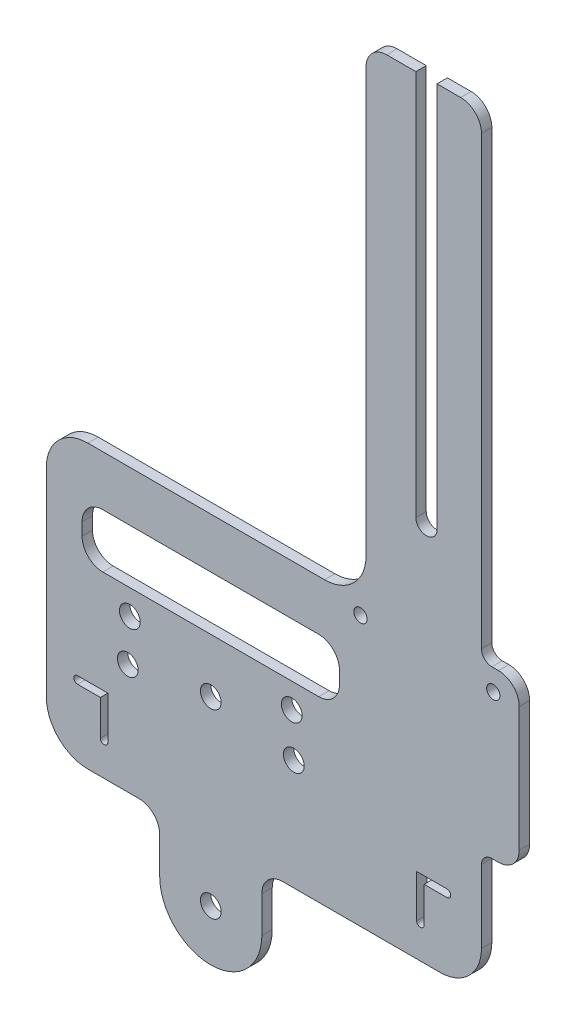
from build123d import *

# Parameters (mm, degrees)
SKETCH1_W           = 200
SKETCH1_H           = 300
SKETCH1_W_2         = 96.214780988
SKETCH1_H_2         = 20
BOSS_EXTRUDE1_DEPTH = 2.5
SKETCH2_R           = 2.5
CUT_EXTRUDE1_DEPTH  = 10
CUT_EXTRUDE3_DEPTH  = 10
CUT_EXTRUDE4_REACH  = 182.936
SKETCH5_W           = 62
SKETCH5_H           = 13
FILLET2_R           = 5
FILLET3_R           = 10
FILLET4_R           = 5
CUT_EXTRUDE6_REACH  = 182.936
SKETCH7_R           = 1.6
FILLET5_R           = 2.5
CUT_EXTRUDE7_REACH  = 182.936
SKETCH8_R           = 2.5


with BuildPart() as part:
    # Sketch1 → Boss-Extrude1 (new body)
    with BuildSketch(Plane.XY):
        Rectangle(SKETCH1_W, SKETCH1_H)
        with Locations((51.892609506, 160)):
            Rectangle(SKETCH1_W_2, SKETCH1_H_2)
    extrude(amount=BOSS_EXTRUDE1_DEPTH)

    # Sketch2 → Cut-Extrude1 (cut)
    with BuildSketch(Plane.XY.offset(2.5)):
        with Locations((-12.4, -28.75)):
            Circle(SKETCH2_R)
        with Locations((7.6, 11.65)):
            Circle(SKETCH2_R)
        with Locations((-32.4, 11.65)):
            Circle(SKETCH2_R)
        Polygon((-44.5, 1.45), (-44.5, 3.25), (-37.2, 3.25), (-37.2, -7.05), (-39, -7.05), (-39, 1.45), align=None)
        Polygon((39, 1.45), (44.5, 1.45), (44.5, 3.25), (37.2, 3.25), (37.2, -7.05), (39, -7.05), align=None)
        with BuildLine():
            Line((-44.5, 1.45), (-44.5, 3.25))
            ThreePointArc((-44.5, 3.25), (-45.4, 2.35), (-44.5, 1.45))
        make_face()
        with BuildLine():
            ThreePointArc((-37.2, -7.05), (-38.1, -7.95), (-39, -7.05))
            Line((-39, -7.05), (-37.2, -7.05))
        make_face()
        with BuildLine():
            ThreePointArc((39, -7.05), (38.1, -7.95), (37.2, -7.05))
            Line((37.2, -7.05), (39, -7.05))
        make_face()
        with BuildLine():
            ThreePointArc((44.5, 3.25), (45.4, 2.35), (44.5, 1.45))
            Line((44.5, 1.45), (44.5, 3.25))
        make_face()
    extrude(amount=-CUT_EXTRUDE1_DEPTH, mode=Mode.SUBTRACT)

    # Sketch4 → Cut-Extrude3 (cut)
    with BuildSketch(Plane.XY.offset(2.5)):
        with BuildLine():
            Line((42.1, 170), (37, 170))
            Line((37, 170), (37, 77))
            ThreePointArc((37, 77), (39.55, 74.45), (42.1, 77))
            Line((42.1, 77), (42.1, 170))
        make_face()
        with BuildLine():
            Line((25, 53), (25, 170))
            Line((25, 170), (3.785219012, 170))
            Line((3.785219012, 170), (3.785219012, 150))
            Line((3.785219012, 150), (-100, 150))
            Line((-100, 150), (-100, -150))
            Line((-100, -150), (100, -150))
            Line((100, -150), (100, 170))
            Line((100, 170), (52.8, 170))
            Line((52.8, 170), (52.8, 55))
            Line((52.8, 55), (61.9, 55))
            Line((61.9, 55), (61.9, 15))
            Line((61.9, 15), (52.8, 15))
            Line((52.8, 15), (52.8, -15))
            Line((52.8, -15), (-0.095794877, -15))
            Line((-0.095794877, -15), (-0.095794877, -28.75))
            ThreePointArc((-0.095794877, -28.75), (-12.4, -41.054205123), (-24.704205123, -28.75))
            Line((-24.704205123, -28.75), (-24.704205123, -15))
            Line((-24.704205123, -15), (-52, -15))
            Line((-52, -15), (-52, 53))
            Line((-52, 53), (25, 53))
        make_face()
    extrude(amount=-CUT_EXTRUDE3_DEPTH, mode=Mode.SUBTRACT)

    # Sketch5 → Cut-Extrude4 (cut, up to next)
    with BuildSketch(Plane.XY.offset(2.5), mode=Mode.PRIVATE) as cut_extrude4_sk1:
        with Locations((-12.4, 34.409289568)):
            Rectangle(SKETCH5_W, SKETCH5_H)
    cut_extrude4_tool1 = extrude(cut_extrude4_sk1.sketch, amount=-CUT_EXTRUDE4_REACH, mode=Mode.PRIVATE) & part.part
    add(cut_extrude4_tool1.solids().sort_by_distance((-12.4, 34.40929, 2.5))[0], mode=Mode.SUBTRACT)

    # Fillet2
    fillet2_edges = [part.edges().sort_by_distance(p)[0] for p in [
        (-43.4, 40.909289568, 1.25),
        (18.6, 40.909289568, 1.25),
        (18.6, 27.909289568, 1.25),
        (-43.4, 27.909289568, 1.25),
    ]]
    fillet(fillet2_edges, radius=FILLET2_R)

    # Fillet3
    fillet3_edges = [part.edges().sort_by_distance(p)[0] for p in [
        (52.8, -15, 1.25),
        (25, 53, 1.25),
        (-52, 53, 1.25),
        (-52, -15, 1.25),
    ]]
    fillet(fillet3_edges, radius=FILLET3_R)

    # Fillet4
    fillet4_edges = [part.edges().sort_by_distance(p)[0] for p in [
        (-0.095794877, -15, 1.25),
        (61.9, 15, 1.25),
        (61.9, 55, 1.25),
        (-24.704205123, -15, 1.25),
        (25, 170, 1.25),
        (52.8, 170, 1.25),
    ]]
    fillet(fillet4_edges, radius=FILLET4_R)

    # Sketch7 → Cut-Extrude6 (cut, up to next)
    with BuildSketch(Plane.XY.offset(2.5), mode=Mode.PRIVATE) as cut_extrude6_sk1:
        with Locations((55.65, 49.91)):
            Circle(SKETCH7_R)
    cut_extrude6_tool1 = extrude(cut_extrude6_sk1.sketch, amount=-CUT_EXTRUDE6_REACH, mode=Mode.PRIVATE) & part.part
    # Sketch7 → Cut-Extrude6 (cut, up to next)
    with BuildSketch(Plane.XY.offset(2.5), mode=Mode.PRIVATE) as cut_extrude6_sk2:
        with Locations((23.65, 49.91)):
            Circle(SKETCH7_R)
    cut_extrude6_tool2 = extrude(cut_extrude6_sk2.sketch, amount=-CUT_EXTRUDE6_REACH, mode=Mode.PRIVATE) & part.part
    add(cut_extrude6_tool1.solids().sort_by_distance((55.65, 49.91, 2.5))[0], mode=Mode.SUBTRACT)
    add(cut_extrude6_tool2.solids().sort_by_distance((23.65, 49.91, 2.5))[0], mode=Mode.SUBTRACT)

    # Fillet5
    fillet5_edges = [part.edges().sort_by_distance(p)[0] for p in [
        (52.8, 15, 1.25),
        (52.8, 55, 1.25),
    ]]
    fillet(fillet5_edges, radius=FILLET5_R)

    # Sketch8 → Cut-Extrude7 (cut, up to next)
    with BuildSketch(Plane.XY.offset(2.5), mode=Mode.PRIVATE) as cut_extrude7_sk1:
        with Locations((7.1, 21.909289568)):
            Circle(SKETCH8_R)
    cut_extrude7_tool1 = extrude(cut_extrude7_sk1.sketch, amount=-CUT_EXTRUDE7_REACH, mode=Mode.PRIVATE) & part.part
    # Sketch8 → Cut-Extrude7 (cut, up to next)
    with BuildSketch(Plane.XY.offset(2.5), mode=Mode.PRIVATE) as cut_extrude7_sk2:
        with Locations((-31.9, 21.909289568)):
            Circle(SKETCH8_R)
    cut_extrude7_tool2 = extrude(cut_extrude7_sk2.sketch, amount=-CUT_EXTRUDE7_REACH, mode=Mode.PRIVATE) & part.part
    # Sketch8 → Cut-Extrude7 (cut, up to next)
    with BuildSketch(Plane.XY.offset(2.5), mode=Mode.PRIVATE) as cut_extrude7_sk3:
        with Locations((-12.4, 14.909289568)):
            Circle(SKETCH8_R)
    cut_extrude7_tool3 = extrude(cut_extrude7_sk3.sketch, amount=-CUT_EXTRUDE7_REACH, mode=Mode.PRIVATE) & part.part
    add(cut_extrude7_tool1.solids().sort_by_distance((7.1, 21.90929, 2.5))[0], mode=Mode.SUBTRACT)
    add(cut_extrude7_tool2.solids().sort_by_distance((-31.9, 21.90929, 2.5))[0], mode=Mode.SUBTRACT)
    add(cut_extrude7_tool3.solids().sort_by_distance((-12.4, 14.90929, 2.5))[0], mode=Mode.SUBTRACT)


solid = part.part
